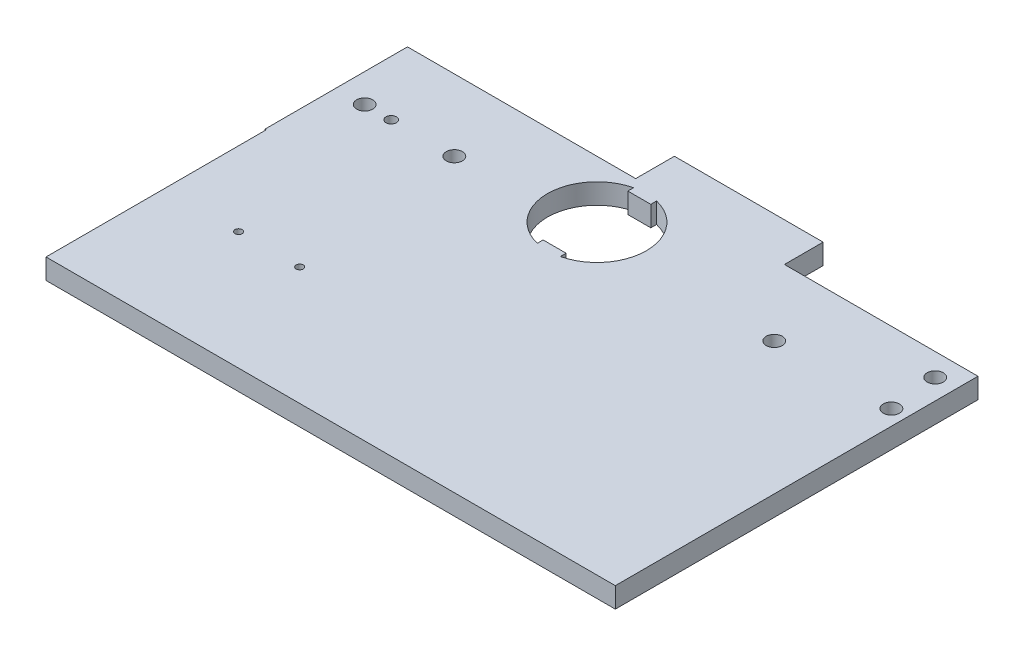
from build123d import *

# Parameters (mm, degrees)
SKETCH1_W            = 280
SKETCH1_H            = 70
SKETCH1_R            = 3.96875
SKETCH1_R_2          = 2.55
BOSS_EXTRUDE7_DEPTH  = 10
SKETCH2_W            = 279.4
SKETCH2_H            = 10
BOSS_EXTRUDE8_DEPTH  = 108
CUT_EXTRUDE2_DEPTH   = 301.273208928
SKETCH3_7_R          = 1.7526
CUT_EXTRUDE3_DEPTH   = 35
SKETCH3_8_R          = 1.7526
CUT_EXTRUDE4_DEPTH   = 32
SKETCH2_3_W          = 279.4
SKETCH2_3_H          = 10
BOSS_EXTRUDE9_DEPTH  = 10
SKETCH10_W           = 73
SKETCH10_H           = 10
BOSS_EXTRUDE11_DEPTH = 19


with BuildPart() as part:
    # Sketch1 → Boss-Extrude7 (new body)
    with BuildSketch(Plane(origin=(0, 0, 0), x_dir=(1, 0, 0), z_dir=(0, 1, 0))):
        with Locations((140, 35)):
            Rectangle(SKETCH1_W, SKETCH1_H)
        with Locations((14, 35)):
            Circle(SKETCH1_R, mode=Mode.SUBTRACT)
        with Locations((27, 35)):
            Circle(SKETCH1_R_2, mode=Mode.SUBTRACT)
        with Locations((58, 35)):
            Circle(SKETCH1_R, mode=Mode.SUBTRACT)
        with Locations((215, 35)):
            Circle(SKETCH1_R, mode=Mode.SUBTRACT)
        with Locations((272.5, 35)):
            Circle(SKETCH1_R, mode=Mode.SUBTRACT)
        with Locations((270, 59)):
            Circle(SKETCH1_R, mode=Mode.SUBTRACT)
    extrude(amount=BOSS_EXTRUDE7_DEPTH)

    # Sketch2 → Boss-Extrude8 (add)
    with BuildSketch(Plane.XY):
        with Locations((140.3, 5)):
            Rectangle(SKETCH2_W, SKETCH2_H)
    extrude(amount=BOSS_EXTRUDE8_DEPTH)

    # Sketch3 → Cut-Extrude2 (cut, through all)
    with BuildSketch(Plane(origin=(0, 10, 0), x_dir=(1, 0, 0), z_dir=(0, 1, 0))):
        with BuildLine():
            Line((115.360720333, 62.78), (115.360720333, 65.616031098))
            ThreePointArc((115.360720333, 65.616031098), (96.72, 42), (115.360720333, 18.383968902))
            Line((115.360720333, 18.383968902), (115.360720333, 21.22))
            Line((115.360720333, 21.22), (126.639279667, 21.22))
            Line((126.639279667, 21.22), (126.639279667, 18.383968902))
            ThreePointArc((126.639279667, 18.383968902), (140.058332959, 26.956784092), (145.28, 42))
            ThreePointArc((145.28, 42), (140.058332959, 57.043215908), (126.639279667, 65.616031098))
            Line((126.639279667, 65.616031098), (126.639279667, 62.78))
            Line((126.639279667, 62.78), (115.360720333, 62.78))
        make_face()
    extrude(amount=-CUT_EXTRUDE2_DEPTH, mode=Mode.SUBTRACT)

    # Sketch3_7 → Cut-Extrude3 (cut)
    with BuildSketch(Plane(origin=(0, 10, 0), x_dir=(1, 0, 0), z_dir=(0, 1, 0))):
        with Locations((37.1, -50)):
            Circle(SKETCH3_7_R)
    extrude(amount=-CUT_EXTRUDE3_DEPTH, mode=Mode.SUBTRACT)

    # Sketch3_8 → Cut-Extrude4 (cut)
    with BuildSketch(Plane(origin=(0, 10, 0), x_dir=(1, 0, 0), z_dir=(0, 1, 0))):
        with Locations((67.1, -50)):
            Circle(SKETCH3_8_R)
    extrude(amount=-CUT_EXTRUDE4_DEPTH, mode=Mode.SUBTRACT)

    # Sketch2_3 → Boss-Extrude9 (add)
    with BuildSketch(Plane.XY):
        with Locations((140.3, 5)):
            Rectangle(SKETCH2_3_W, SKETCH2_3_H)
    extrude(amount=BOSS_EXTRUDE9_DEPTH)

    # Sketch10 → Boss-Extrude11 (add)
    with BuildSketch(Plane(origin=(0, 0, -70), x_dir=(-1, 0, 0), z_dir=(0, 0, -1))):
        with Locations((-148.5, 5)):
            Rectangle(SKETCH10_W, SKETCH10_H)
    extrude(amount=BOSS_EXTRUDE11_DEPTH)


solid = part.part
